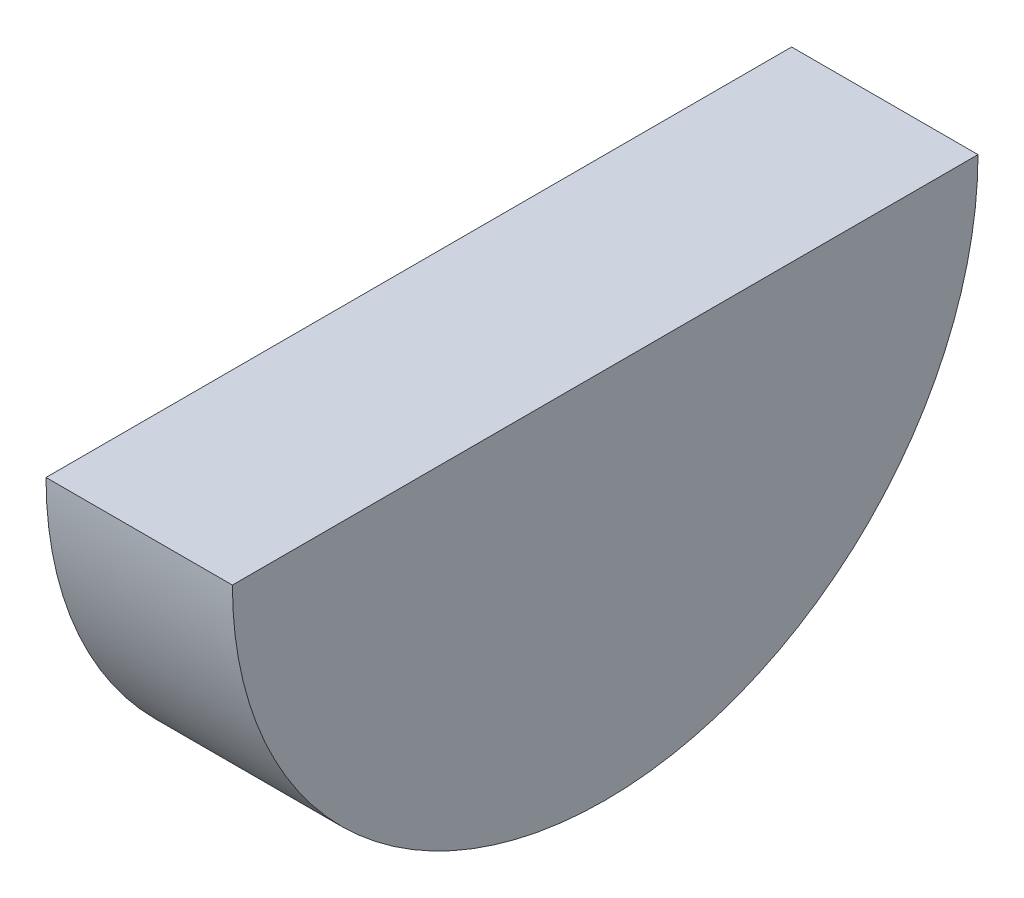
from build123d import *

# Parameters (mm, degrees)
BOSS_EXTRUDE1_DEPTH = 38.1


with BuildPart() as part:
    # Sketch1 → Boss-Extrude1 (new body)
    with BuildSketch(Plane(origin=(0, 0, 0), x_dir=(0, 0, -1), z_dir=(1, 0, 0))):
        with BuildLine():
            Line((76.2, 0), (-76.2, 0))
            ThreePointArc((-76.2, 0), (0, -76.2), (76.2, 0))
        make_face()
    extrude(amount=BOSS_EXTRUDE1_DEPTH)


solid = part.part
